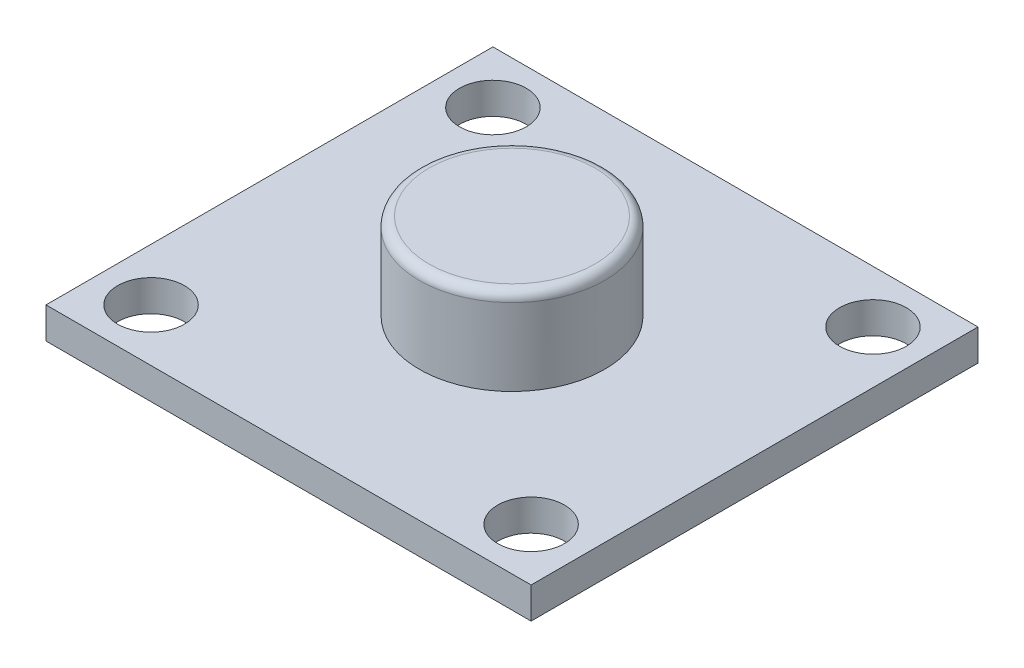
from build123d import *

# Parameters (mm, degrees)
SKETCH1_W           = 25.4
SKETCH1_H           = 23.4
BOSS_EXTRUDE1_DEPTH = 1.64
SKETCH2_R           = 1.75
CUT_EXTRUDE1_DEPTH  = 2.64
SKETCH3_R           = 4.85
BOSS_EXTRUDE2_DEPTH = 4.53
FILLET1_R           = 0.5


with BuildPart() as part:
    # Sketch1 → Boss-Extrude1 (new body)
    with BuildSketch(Plane(origin=(0, 0, 0), x_dir=(1, 0, 0), z_dir=(0, 1, 0))):
        Rectangle(SKETCH1_W, SKETCH1_H)
    extrude(amount=BOSS_EXTRUDE1_DEPTH)

    # Sketch2 → Cut-Extrude1 (cut, through all)
    with BuildSketch(Plane(origin=(0, 1.64, 0), x_dir=(1, 0, 0), z_dir=(0, 1, 0))):
        with Locations((-9.95, -8.95)):
            Circle(SKETCH2_R)
        with Locations((9.95, -8.95)):
            Circle(SKETCH2_R)
        with Locations((9.95, 8.95)):
            Circle(SKETCH2_R)
        with Locations((-9.95, 8.95)):
            Circle(SKETCH2_R)
    extrude(amount=-CUT_EXTRUDE1_DEPTH, mode=Mode.SUBTRACT)

    # Sketch3 → Boss-Extrude2 (add)
    with BuildSketch(Plane(origin=(0, 1.64, 0), x_dir=(1, 0, 0), z_dir=(0, 1, 0))):
        Circle(SKETCH3_R)
    extrude(amount=BOSS_EXTRUDE2_DEPTH)

    # Fillet1
    fillet1_edges = [part.edges().sort_by_distance(p)[0] for p in [
        (-4.85, 6.17, 0),
    ]]
    fillet(fillet1_edges, radius=FILLET1_R)


solid = part.part
